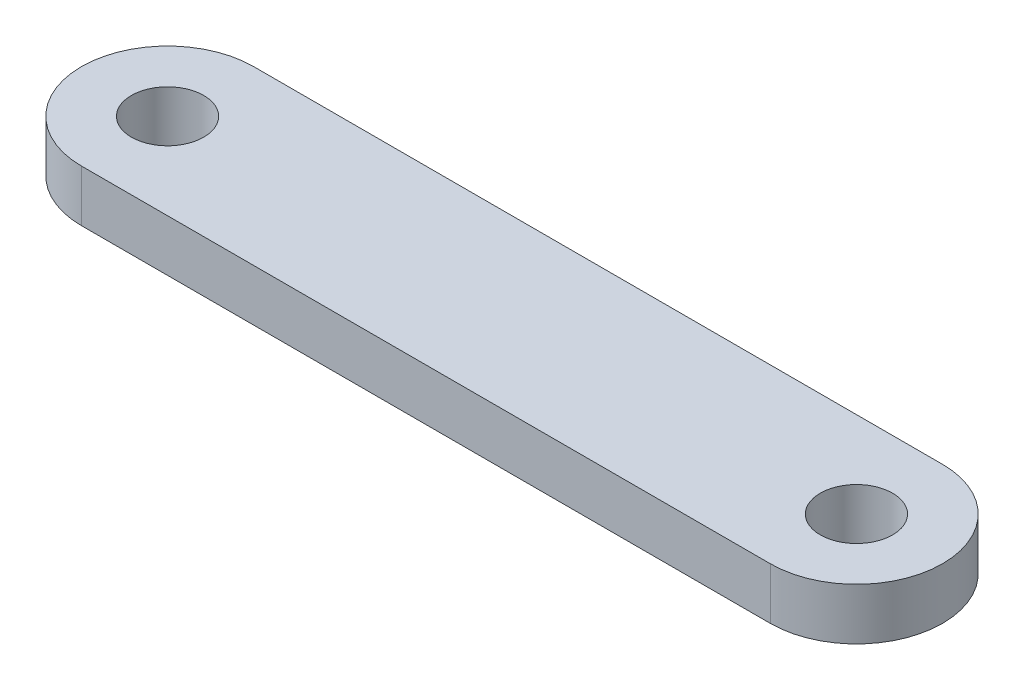
from build123d import *

# Parameters (mm, degrees)
BOSS_EXTRUDE2_DEPTH = 3
SKETCH3_R           = 2.1
CUT_EXTRUDE3_DEPTH  = 4


with BuildPart() as part:
    # Sketch1 → Boss-Extrude2 (new body)
    with BuildSketch(Plane(origin=(0, 0, 0), x_dir=(1, 0, 0), z_dir=(0, 1, 0))):
        with BuildLine():
            Line((20, -5), (-20, -5))
            ThreePointArc((-20, -5), (-25, 0), (-20, 5))
            Line((-20, 5), (20, 5))
            ThreePointArc((20, 5), (25, 0), (20, -5))
        make_face()
    extrude(amount=BOSS_EXTRUDE2_DEPTH)

    # Sketch3 → Cut-Extrude3 (cut, through all)
    with BuildSketch(Plane(origin=(0, 3, 0), x_dir=(1, 0, 0), z_dir=(0, 1, 0))):
        with Locations(Location((-20, 0, 0), (0, 0, 270))):  # turned: the seam where the file's is
            Circle(SKETCH3_R)
    cut_extrude3 = extrude(amount=-CUT_EXTRUDE3_DEPTH, mode=Mode.SUBTRACT)

    # Mirror1: Cut-Extrude3 across plane
    add(cut_extrude3.mirror(Plane(origin=(0, 0, 0), x_dir=(0, 0, 1), z_dir=(1, 0, 0))), mode=Mode.SUBTRACT)


solid = part.part
